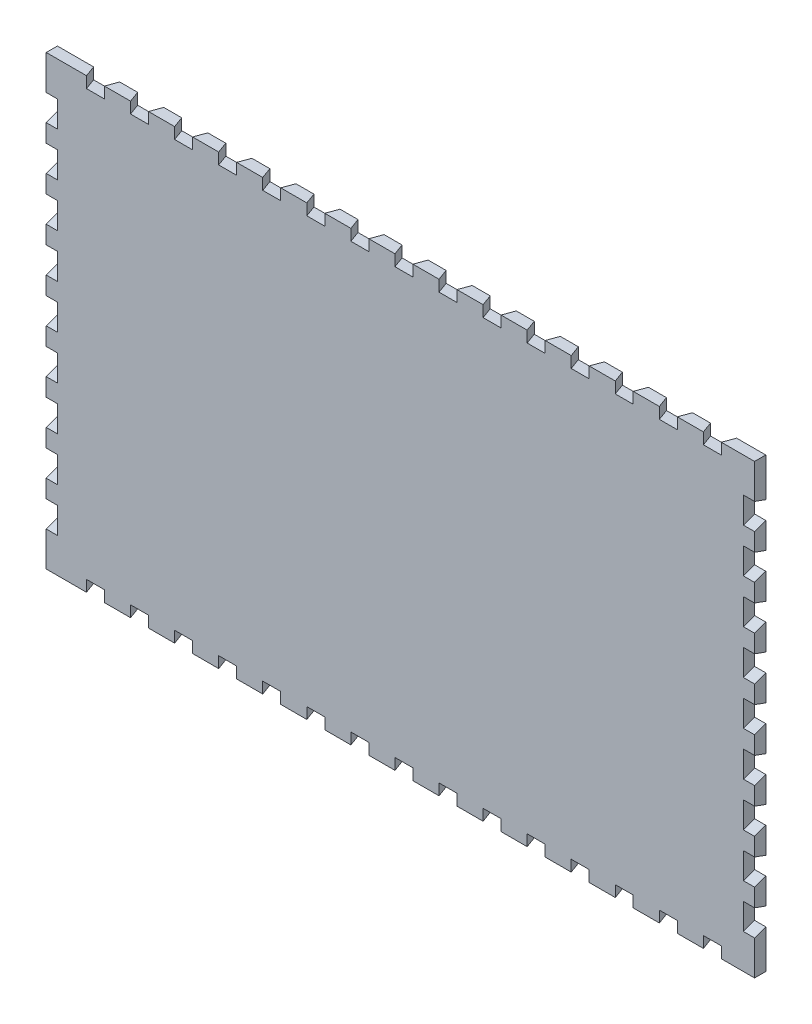
from build123d import *

# Parameters (mm, degrees)
BOSS_EXTRUDE1_DEPTH = 3
CUT_EXTRUDE1_DEPTH  = 3
CUT_EXTRUDE3_START  = -117
CUT_EXTRUDE3_DEPTH  = 187
CUT_EXTRUDE5_DEPTH  = 3
CUT_EXTRUDE6_START  = -187
CUT_EXTRUDE6_DEPTH  = 3


with BuildPart() as part:
    # Sketch1 → Boss-Extrude1 (new body)
    with BuildSketch(Plane.XY):
        Polygon((10, 0), (190, 0), (190, 120), (9.862497021, 120), (0, 120), (0, 0), align=None)
    extrude(amount=BOSS_EXTRUDE1_DEPTH)

    # Sketch3 → Cut-Extrude1 (cut)
    with BuildSketch(Plane(origin=(0, 120, 0), x_dir=(1, 0, 0), z_dir=(0, 1, 0))):
        Polygon((181.0916961, -3), (182.183607, 0), (175.183607, 0), (176.275517, -3), align=None)
        Polygon((169.2716961, -3), (170.363607, 0), (163.363607, 0), (164.455517, -3), align=None)
        Polygon((157.4516961, -3), (158.543607, 0), (151.543607, 0), (152.635517, -3), align=None)
        Polygon((145.6316961, -3), (146.723607, 0), (139.723607, 0), (140.815517, -3), align=None)
        Polygon((133.8116961, -3), (134.903607, 0), (127.903607, 0), (128.995517, -3), align=None)
        Polygon((121.9916961, -3), (123.083607, 0), (116.083607, 0), (117.175517, -3), align=None)
        Polygon((110.1716961, -3), (111.263607, 0), (104.263607, 0), (105.355517, -3), align=None)
        Polygon((98.3516961, -3), (99.443607, 0), (92.443607, 0), (93.535517, -3), align=None)
        Polygon((86.5316961, -3), (87.623607, 0), (80.623607, 0), (81.715517, -3), align=None)
        Polygon((74.7116961, -3), (75.803607, 0), (68.803607, 0), (69.895517, -3), align=None)
        Polygon((62.8916961, -3), (63.983607, 0), (56.983607, 0), (58.075517, -3), align=None)
        Polygon((51.0716961, -3), (52.163607, 0), (45.163607, 0), (46.255517, -3), align=None)
        Polygon((39.2516961, -3), (40.343607, 0), (33.343607, 0), (34.435517, -3), align=None)
        Polygon((27.4316961, -3), (28.523607, 0), (21.523607, 0), (22.615517, -3), align=None)
        Polygon((15.6116961, -3), (16.703607, 0), (9.703607, 0), (10.795517, -3), align=None)
        Polygon((232.620596447, -14.855202406), (233.712507347, -11.855202406), (226.712507347, -11.855202406), (227.804417347, -14.855202406), align=None)
    extrude(amount=-CUT_EXTRUDE1_DEPTH, mode=Mode.SUBTRACT)

    # Sketch3_2 → Cut-Extrude3 (cut)
    with BuildSketch(Plane(origin=(0, 120, 0), x_dir=(1, 0, 0), z_dir=(0, 1, 0)).offset(CUT_EXTRUDE3_START)):
        Polygon((181.0916961, -3), (182.183607, 0), (175.183607, 0), (176.275517, -3), align=None)
        Polygon((169.2716961, -3), (170.363607, 0), (163.363607, 0), (164.455517, -3), align=None)
        Polygon((157.4516961, -3), (158.543607, 0), (151.543607, 0), (152.635517, -3), align=None)
        Polygon((145.6316961, -3), (146.723607, 0), (139.723607, 0), (140.815517, -3), align=None)
        Polygon((133.8116961, -3), (134.903607, 0), (127.903607, 0), (128.995517, -3), align=None)
        Polygon((121.9916961, -3), (123.083607, 0), (116.083607, 0), (117.175517, -3), align=None)
        Polygon((110.1716961, -3), (111.263607, 0), (104.263607, 0), (105.355517, -3), align=None)
        Polygon((98.3516961, -3), (99.443607, 0), (92.443607, 0), (93.535517, -3), align=None)
        Polygon((86.5316961, -3), (87.623607, 0), (80.623607, 0), (81.715517, -3), align=None)
        Polygon((74.7116961, -3), (75.803607, 0), (68.803607, 0), (69.895517, -3), align=None)
        Polygon((62.8916961, -3), (63.983607, 0), (56.983607, 0), (58.075517, -3), align=None)
        Polygon((51.0716961, -3), (52.163607, 0), (45.163607, 0), (46.255517, -3), align=None)
        Polygon((39.2516961, -3), (40.343607, 0), (33.343607, 0), (34.435517, -3), align=None)
        Polygon((27.4316961, -3), (28.523607, 0), (21.523607, 0), (22.615517, -3), align=None)
        Polygon((15.6116961, -3), (16.703607, 0), (9.703607, 0), (10.795517, -3), align=None)
        Polygon((232.620596447, -14.855202406), (233.712507347, -11.855202406), (226.712507347, -11.855202406), (227.804417347, -14.855202406), align=None)
    extrude(amount=-CUT_EXTRUDE3_DEPTH, mode=Mode.SUBTRACT)

    # Sketch6 → Cut-Extrude5 (cut)
    with BuildSketch(Plane.ZY):
        Polygon((0, 104.7919109), (3, 103.7), (3, 110.7), (0, 109.60809), align=None)
        Polygon((0, 92.9919109), (3, 91.9), (3, 98.9), (0, 97.80809), align=None)
        Polygon((0, 81.1919109), (3, 80.1), (3, 87.1), (0, 86.00809), align=None)
        Polygon((0, 69.3919109), (3, 68.3), (3, 75.3), (0, 74.20809), align=None)
        Polygon((0, 57.5919109), (3, 56.5), (3, 63.5), (0, 62.40809), align=None)
        Polygon((0, 45.7919109), (3, 44.7), (3, 51.7), (0, 50.60809), align=None)
        Polygon((0, 33.9919109), (3, 32.9), (3, 39.9), (0, 38.80809), align=None)
        Polygon((0, 22.1919109), (3, 21.1), (3, 28.1), (0, 27.00809), align=None)
        Polygon((0, 10.3919109), (3, 9.3), (3, 16.3), (0, 15.20809), align=None)
    extrude(amount=-CUT_EXTRUDE5_DEPTH, mode=Mode.SUBTRACT)

    # Sketch6_3 → Cut-Extrude6 (cut)
    with BuildSketch(Plane.ZY.offset(CUT_EXTRUDE6_START)):
        Polygon((0, 104.7919109), (3, 103.7), (3, 110.7), (0, 109.60809), align=None)
        Polygon((0, 92.9919109), (3, 91.9), (3, 98.9), (0, 97.80809), align=None)
        Polygon((0, 81.1919109), (3, 80.1), (3, 87.1), (0, 86.00809), align=None)
        Polygon((0, 69.3919109), (3, 68.3), (3, 75.3), (0, 74.20809), align=None)
        Polygon((0, 57.5919109), (3, 56.5), (3, 63.5), (0, 62.40809), align=None)
        Polygon((0, 45.7919109), (3, 44.7), (3, 51.7), (0, 50.60809), align=None)
        Polygon((0, 33.9919109), (3, 32.9), (3, 39.9), (0, 38.80809), align=None)
        Polygon((0, 22.1919109), (3, 21.1), (3, 28.1), (0, 27.00809), align=None)
        Polygon((0, 10.3919109), (3, 9.3), (3, 16.3), (0, 15.20809), align=None)
    extrude(amount=-CUT_EXTRUDE6_DEPTH, mode=Mode.SUBTRACT)


solid = part.part
